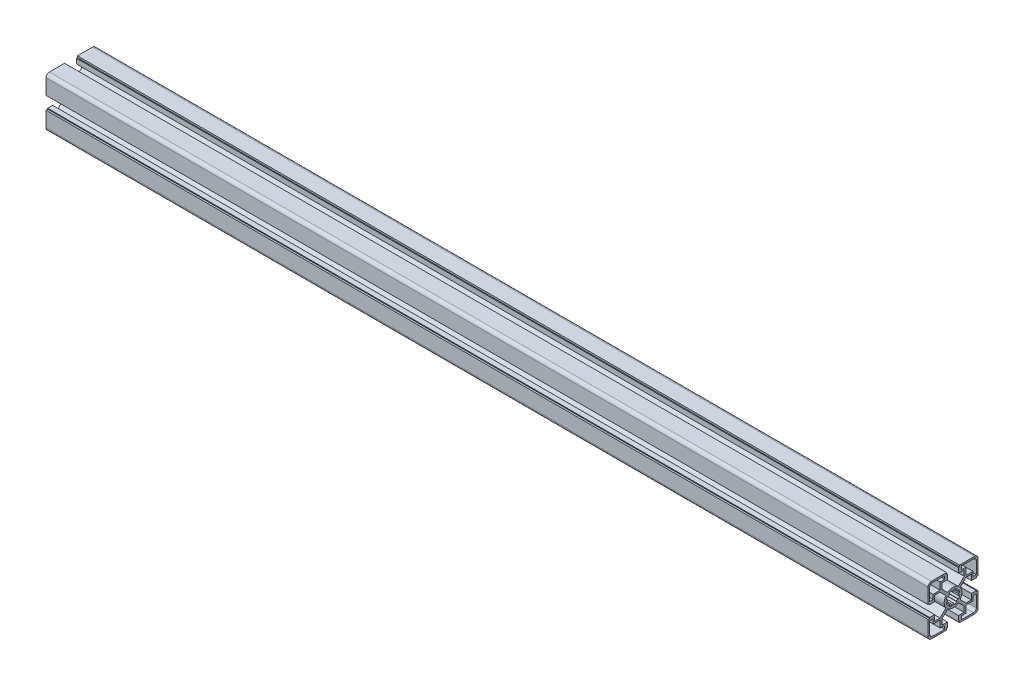
from build123d import *

# Parameters (mm, degrees)
BR_EXTRUDE_DEPTH      = 397.5
BR_EXTRUDE_DEPTH_BACK = 397.5


with BuildPart() as part:
    # Sketch2 → BR_Extrude (new body, two sides)
    with BuildSketch(Plane(origin=(0, 0, 0), x_dir=(0, 0, -1), z_dir=(1, 0, 0))) as br_extrude_sk:
        with BuildLine():
            Line((-10.05, 11.676345597), (-10.05, 16.5))
            Line((-10.05, 16.5), (-5, 16.5))
            Line((-5, 16.5), (-5, 21))
            Line((-5, 21), (-5.8, 21))
            Line((-5.8, 21), (-5.8, 22.5))
            Line((-5.8, 22.5), (-19.5, 22.5))
            ThreePointArc((-19.5, 22.5), (-21.621320344, 21.621320344), (-22.5, 19.5))
            Line((-22.5, 19.5), (-22.5, 5.8))
            Line((-22.5, 5.8), (-21, 5.8))
            Line((-21, 5.8), (-21, 5))
            Line((-21, 5), (-16.5, 5))
            Line((-16.5, 5), (-16.5, 10.05))
            Line((-16.5, 10.05), (-11.676345597, 10.05))
            Line((-11.676345597, 10.05), (-6.411275155, 4.784929559))
            ThreePointArc((-6.411275155, 4.784929559), (-8, 0), (-6.411275155, -4.784929559))
            Line((-6.411275155, -4.784929559), (-11.676345597, -10.05))
            Line((-11.676345597, -10.05), (-16.5, -10.05))
            Line((-16.5, -10.05), (-16.5, -5))
            Line((-16.5, -5), (-21, -5))
            Line((-21, -5), (-21, -5.8))
            Line((-21, -5.8), (-22.5, -5.8))
            Line((-22.5, -5.8), (-22.5, -19.5))
            ThreePointArc((-22.5, -19.5), (-21.621320344, -21.621320344), (-19.5, -22.5))
            Line((-19.5, -22.5), (-5.8, -22.5))
            Line((-5.8, -22.5), (-5.8, -21))
            Line((-5.8, -21), (-5, -21))
            Line((-5, -21), (-5, -16.5))
            Line((-5, -16.5), (-10.05, -16.5))
            Line((-10.05, -16.5), (-10.05, -11.676345597))
            Line((-10.05, -11.676345597), (-4.784929559, -6.411275155))
            ThreePointArc((-4.784929559, -6.411275155), (0, -8), (4.784929559, -6.411275155))
            Line((4.784929559, -6.411275155), (10.05, -11.676345597))
            Line((10.05, -11.676345597), (10.05, -16.5))
            Line((10.05, -16.5), (5, -16.5))
            Line((5, -16.5), (5, -21))
            Line((5, -21), (5.8, -21))
            Line((5.8, -21), (5.8, -22.5))
            Line((5.8, -22.5), (19.5, -22.5))
            ThreePointArc((19.5, -22.5), (21.621320344, -21.621320344), (22.5, -19.5))
            Line((22.5, -19.5), (22.5, -5.8))
            Line((22.5, -5.8), (21, -5.8))
            Line((21, -5.8), (21, -5))
            Line((21, -5), (16.5, -5))
            Line((16.5, -5), (16.5, -10.05))
            Line((16.5, -10.05), (11.676345597, -10.05))
            Line((11.676345597, -10.05), (6.411275155, -4.784929559))
            ThreePointArc((6.411275155, -4.784929559), (8, 0), (6.411275155, 4.784929559))
            Line((6.411275155, 4.784929559), (11.676345597, 10.05))
            Line((11.676345597, 10.05), (16.5, 10.05))
            Line((16.5, 10.05), (16.5, 5))
            Line((16.5, 5), (21, 5))
            Line((21, 5), (21, 5.8))
            Line((21, 5.8), (22.5, 5.8))
            Line((22.5, 5.8), (22.5, 19.5))
            ThreePointArc((22.5, 19.5), (21.621320344, 21.621320344), (19.5, 22.5))
            Line((19.5, 22.5), (5.8, 22.5))
            Line((5.8, 22.5), (5.8, 21))
            Line((5.8, 21), (5, 21))
            Line((5, 21), (5, 16.5))
            Line((5, 16.5), (10.05, 16.5))
            Line((10.05, 16.5), (10.05, 11.676345597))
            Line((10.05, 11.676345597), (4.784929559, 6.411275155))
            ThreePointArc((4.784929559, 6.411275155), (0, 8), (-4.784929559, 6.411275155))
            Line((-4.784929559, 6.411275155), (-10.05, 11.676345597))
        make_face()
        with BuildLine():
            Line((11.55, 11.55), (11.55, 18))
            Line((11.55, 18), (7.5, 18))
            Line((7.5, 18), (7.5, 21))
            Line((7.5, 21), (18.5, 21))
            ThreePointArc((18.5, 21), (20.267766953, 20.267766953), (21, 18.5))
            Line((21, 18.5), (21, 7.5))
            Line((21, 7.5), (18, 7.5))
            Line((18, 7.5), (18, 11.55))
            Line((18, 11.55), (11.55, 11.55))
        make_face(mode=Mode.SUBTRACT)
        with BuildLine():
            Line((11.55, -11.55), (18, -11.55))
            Line((18, -11.55), (18, -7.5))
            Line((18, -7.5), (21, -7.5))
            Line((21, -7.5), (21, -18.5))
            ThreePointArc((21, -18.5), (20.267766953, -20.267766953), (18.5, -21))
            Line((18.5, -21), (7.5, -21))
            Line((7.5, -21), (7.5, -18))
            Line((7.5, -18), (11.55, -18))
            Line((11.55, -18), (11.55, -11.55))
        make_face(mode=Mode.SUBTRACT)
        with BuildLine():
            Line((-11.55, 11.55), (-18, 11.55))
            Line((-18, 11.55), (-18, 7.5))
            Line((-18, 7.5), (-21, 7.5))
            Line((-21, 7.5), (-21, 18.5))
            ThreePointArc((-21, 18.5), (-20.267766953, 20.267766953), (-18.5, 21))
            Line((-18.5, 21), (-7.5, 21))
            Line((-7.5, 21), (-7.5, 18))
            Line((-7.5, 18), (-11.55, 18))
            Line((-11.55, 18), (-11.55, 11.55))
        make_face(mode=Mode.SUBTRACT)
        with BuildLine():
            Line((-11.55, -11.55), (-11.55, -18))
            Line((-11.55, -18), (-7.5, -18))
            Line((-7.5, -18), (-7.5, -21))
            Line((-7.5, -21), (-18.5, -21))
            ThreePointArc((-18.5, -21), (-20.267766953, -20.267766953), (-21, -18.5))
            Line((-21, -18.5), (-21, -7.5))
            Line((-21, -7.5), (-18, -7.5))
            Line((-18, -7.5), (-18, -11.55))
            Line((-18, -11.55), (-11.55, -11.55))
        make_face(mode=Mode.SUBTRACT)
        with BuildLine():
            Line((-6.007327293, -1.059253884), (-4.924038765, -0.868240888))
            ThreePointArc((-4.924038765, -0.868240888), (-5, 0), (-4.924038765, 0.868240888))
            Line((-4.924038765, 0.868240888), (-6.007327293, 1.059253884))
            ThreePointArc((-6.007327293, 1.059253884), (-5.635665148, 2.334368937), (-4.99682747, 3.498816262))
            Line((-4.99682747, 3.498816262), (-4.095760221, 2.867882182))
            ThreePointArc((-4.095760221, 2.867882182), (-3.535533906, 3.535533906), (-2.867882182, 4.095760221))
            Line((-2.867882182, 4.095760221), (-3.498816262, 4.99682747))
            ThreePointArc((-3.498816262, 4.99682747), (-2.334368937, 5.635665148), (-1.059253884, 6.007327293))
            Line((-1.059253884, 6.007327293), (-0.868240888, 4.924038765))
            ThreePointArc((-0.868240888, 4.924038765), (0, 5), (0.868240888, 4.924038765))
            Line((0.868240888, 4.924038765), (1.059253884, 6.007327293))
            ThreePointArc((1.059253884, 6.007327293), (2.334368937, 5.635665148), (3.498816262, 4.99682747))
            Line((3.498816262, 4.99682747), (2.867882182, 4.095760221))
            ThreePointArc((2.867882182, 4.095760221), (3.535533906, 3.535533906), (4.095760221, 2.867882182))
            Line((4.095760221, 2.867882182), (4.99682747, 3.498816262))
            ThreePointArc((4.99682747, 3.498816262), (5.635665148, 2.334368937), (6.007327293, 1.059253884))
            Line((6.007327293, 1.059253884), (4.924038765, 0.868240888))
            ThreePointArc((4.924038765, 0.868240888), (5, 0), (4.924038765, -0.868240888))
            Line((4.924038765, -0.868240888), (6.007327293, -1.059253884))
            ThreePointArc((6.007327293, -1.059253884), (5.635665148, -2.334368937), (4.99682747, -3.498816262))
            Line((4.99682747, -3.498816262), (4.095760221, -2.867882182))
            ThreePointArc((4.095760221, -2.867882182), (3.535533906, -3.535533906), (2.867882182, -4.095760221))
            Line((2.867882182, -4.095760221), (3.498816262, -4.99682747))
            ThreePointArc((3.498816262, -4.99682747), (2.334368937, -5.635665148), (1.059253884, -6.007327293))
            Line((1.059253884, -6.007327293), (0.868240888, -4.924038765))
            ThreePointArc((0.868240888, -4.924038765), (0, -5), (-0.868240888, -4.924038765))
            Line((-0.868240888, -4.924038765), (-1.059253884, -6.007327293))
            ThreePointArc((-1.059253884, -6.007327293), (-2.334368937, -5.635665148), (-3.498816262, -4.99682747))
            Line((-3.498816262, -4.99682747), (-2.867882182, -4.095760221))
            ThreePointArc((-2.867882182, -4.095760221), (-3.535533906, -3.535533906), (-4.095760221, -2.867882182))
            Line((-4.095760221, -2.867882182), (-4.99682747, -3.498816262))
            ThreePointArc((-4.99682747, -3.498816262), (-5.635665148, -2.334368937), (-6.007327293, -1.059253884))
        make_face(mode=Mode.SUBTRACT)
    extrude(amount=BR_EXTRUDE_DEPTH)
    extrude(br_extrude_sk.sketch, amount=-BR_EXTRUDE_DEPTH_BACK)


solid = part.part
